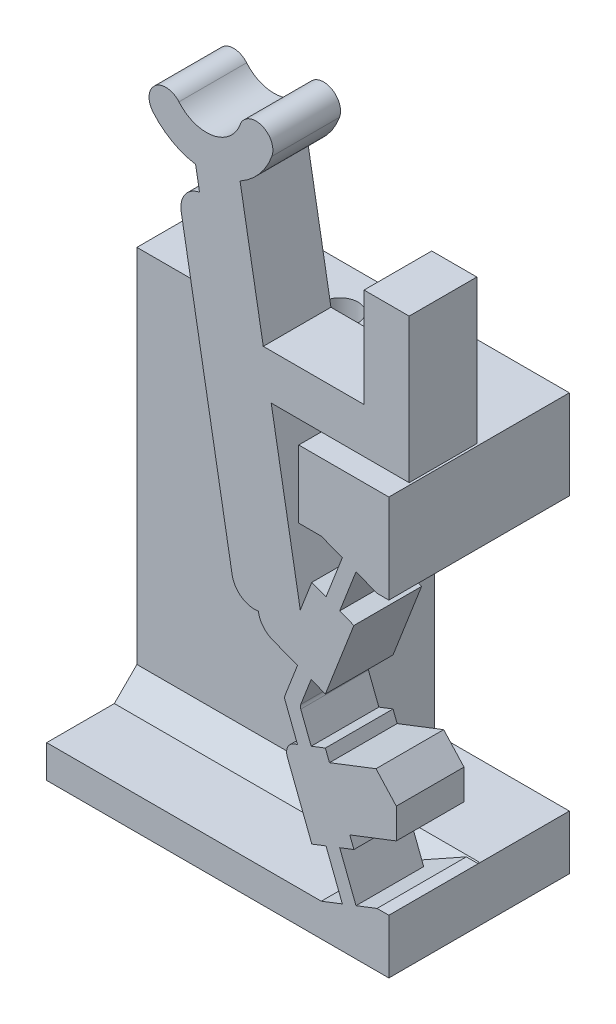
from build123d import *

# Parameters (mm, degrees)
BOSS_SWITCH_BODY_DEPTH            = 3
SKETCH1_W                         = 2.994375291
SKETCH1_H                         = 2.409101515
SKETCH1_W_2                       = 3.994375291
SKETCH1_H_2                       = 3.957767538
BOSS_FLANGE_WIDTH_DEPTH           = 5
BOSS_FLANGE_HEIGHT_REACH          = 36.354
SKETCH2_W                         = 4
SKETCH2_H                         = 3.957767538
SKETCH2_W_2                       = 8
SKETCH2_H_2                       = 1.451333978
SKETCH17_W                        = 15.1675
SKETCH17_H                        = 4
BOSS_FLANGE_SUPPORT_DEPTH         = 13.053634428
CUT_WALL_GAP_DEPTH                = 1
TAP_DRILL_FOR_M2X0_4_TAP1_D       = 1.6
M2_CLEARANCE_HOLE2_D              = 2.4
M2_CLEARANCE_HOLE2_DEPTH          = 13.462735941
CHAMFER_FLANGE_SUPPORT_3_SIZE     = 1
FILLET1_R                         = 1
FILLET2_R                         = 0.5
SKETCH28_W                        = 5.9675
SKETCH28_H                        = 12.095866891
CUT_PRINT_SUPPORT_CLEARANCE_DEPTH = 33.624103931


with BuildPart() as part:
    # Sketch-SwitchBossUp → Boss-Switch Body (new body)
    with BuildSketch(Plane.XY):
        with BuildLine():
            Line((-5.697895702, 26.949658376), (-5.524247524, 25.964850623))
            ThreePointArc((-5.524247524, 25.964850623), (-6.169751391, 25.553619307), (-6.3354071, 24.806394693))
            Line((-6.3354071, 24.806394693), (-4.07798079, 12.003893904))
            ThreePointArc((-4.07798079, 12.003893904), (-3.666749473, 11.358390037), (-2.919524859, 11.192734328))
            Line((-2.919524859, 11.192734328), (-2.816117912, 10.606284387))
            Line((-2.816117912, 10.606284387), (-1.811990528, 10.217060362))
            Line((-1.811990528, 10.217060362), (-1.182618868, 9.973100706))
            Line((-1.182618868, 9.973100706), (-1.735258621, 8.547390389))
            ThreePointArc((-1.735258621, 8.547390389), (-1.752158006, 8.457034961), (-1.735258621, 8.366679532))
            Line((-1.735258621, 8.366679532), (-1.182618868, 6.940969215))
            Line((-1.182618868, 6.940969215), (-1.811990528, 6.697009559))
            Line((-1.811990528, 6.697009559), (-0.547014535, 3.433600952))
            Line((-0.547014535, 3.433600952), (0.082357125, 3.677560608))
            Line((0.082357125, 3.677560608), (0.805200549, 1.81275569))
            Line((0.805200549, 1.81275569), (-0.12720191, 1.451333978))
            Line((-0.12720191, 1.451333978), (-0.12720191, 0))
            Line((-0.12720191, 0), (2.867173381, 0))
            Line((2.867173381, 0), (2.867173381, 2.409101515))
            Line((2.867173381, 2.409101515), (2.343664607, 2.409101515))
            Line((2.343664607, 2.409101515), (1.411262148, 2.047679803))
            Line((1.411262148, 2.047679803), (0.688418723, 3.912484721))
            Line((0.688418723, 3.912484721), (1.317790383, 4.156444377))
            Line((1.317790383, 4.156444377), (1.13533703, 4.627140933))
            Line((1.13533703, 4.627140933), (3.197473995, 5.426475025))
            Line((3.197473995, 5.426475025), (3.197473995, 6.761927069))
            Line((3.197473995, 6.761927069), (2.297289747, 7.748445958))
            Line((2.297289747, 7.748445958), (0.235267743, 6.949156428))
            Line((0.235267743, 6.949156428), (0.05281439, 7.419852984))
            Line((0.05281439, 7.419852984), (-0.57655727, 7.175893328))
            Line((-0.57655727, 7.175893328), (-1.038134762, 8.366679532))
            ThreePointArc((-1.038134762, 8.366679532), (-1.055034148, 8.457034961), (-1.038134762, 8.547390389))
            Line((-1.038134762, 8.547390389), (-0.57655727, 9.738176593))
            Line((-0.57655727, 9.738176593), (0.05281439, 9.494216937))
            Line((0.05281439, 9.494216937), (1.317790383, 12.757625544))
            Line((1.317790383, 12.757625544), (0.688418723, 13.0015852))
            Line((0.688418723, 13.0015852), (1.411262148, 14.866390118))
            Line((1.411262148, 14.866390118), (2.343664607, 14.504968406))
            Line((2.343664607, 14.504968406), (2.867173381, 14.504968406))
            Line((2.867173381, 14.504968406), (2.867173381, 18.462735944))
            Line((2.867173381, 18.462735944), (-0.111637615, 18.462735944))
            Line((-0.111637615, 18.462735944), (-1.12720191, 18.462735944))
            Line((-1.12720191, 18.462735944), (-1.12720191, 15.462735944))
            Line((-1.12720191, 15.462735944), (-0.12720191, 15.462735944))
            Line((-0.12720191, 15.462735944), (0.805200549, 15.101314231))
            Line((0.805200549, 15.101314231), (0.082357125, 13.236509313))
            Line((0.082357125, 13.236509313), (-0.547014535, 13.480468969))
            Line((-0.547014535, 13.480468969), (-1.059112089, 12.159350171))
            Line((-1.059112089, 12.159350171), (-2.346896051, 19.462735944))
            Line((-2.346896051, 19.462735944), (3.767173381, 19.462735944))
            Line((3.767173381, 19.462735944), (3.767173381, 25.857619356))
            Line((3.767173381, 25.857619356), (1.767173381, 25.857619356))
            Line((1.767173381, 25.857619356), (1.767173381, 21.462735944))
            Line((1.767173381, 21.462735944), (-2.699550012, 21.462735944))
            Line((-2.699550012, 21.462735944), (-3.728280196, 27.296954732))
            ThreePointArc((-3.728280196, 27.296954732), (-2.874356585, 27.992742953), (-2.319025652, 28.944012807))
            ThreePointArc((-2.319025652, 28.944012807), (-2.76728001, 29.905297381), (-3.728564583, 29.457043022))
            ThreePointArc((-3.728564583, 29.457043022), (-4.944660137, 28.436617692), (-6.436422172, 28.97957467))
            ThreePointArc((-6.436422172, 28.97957467), (-7.493046212, 29.072017295), (-7.585488837, 28.015393255))
            ThreePointArc((-7.585488837, 28.015393255), (-6.738295005, 27.311426358), (-5.697895702, 26.949658376))
        make_face()
    extrude(amount=BOSS_SWITCH_BODY_DEPTH)

    # Sketch1 → Boss-Flange Width (add)
    with BuildSketch(Plane(origin=(0, 0, 0), x_dir=(-1, 0, 0), z_dir=(0, 0, -1))):
        with Locations((-1.369985736, 1.204550758)):
            Rectangle(SKETCH1_W, SKETCH1_H)
        with Locations((-0.869985736, 16.483852175)):
            Rectangle(SKETCH1_W_2, SKETCH1_H_2)
    extrude(amount=BOSS_FLANGE_WIDTH_DEPTH)

    # Boss-Flange Height: up to this face of the body (flat: up to its plane)
    boss_flange_height_end = Plane(part.part.faces().sort_by_distance((-0.12720191, 1.077409098, -1.438016547))[0])
    # Sketch2 → Boss-Flange Height (add, up to the picked face)
    with BuildSketch(Plane(origin=(-12.300326619, 0, 0), x_dir=(0, 0, -1), z_dir=(1, 0, 0)), mode=Mode.PRIVATE) as boss_flange_height_sk1:
        with Locations((3, 16.483852175)):
            Rectangle(SKETCH2_W, SKETCH2_H)
    boss_flange_height_tool1 = split(extrude(boss_flange_height_sk1.sketch, amount=BOSS_FLANGE_HEIGHT_REACH, mode=Mode.PRIVATE), bisect_by=boss_flange_height_end, keep=Keep.BOTH, mode=Mode.PRIVATE)
    # Sketch2 → Boss-Flange Height (add, up to the picked face)
    with BuildSketch(Plane(origin=(-12.300326619, 0, 0), x_dir=(0, 0, -1), z_dir=(1, 0, 0)), mode=Mode.PRIVATE) as boss_flange_height_sk2:
        with Locations((1, 0.725666989)):
            Rectangle(SKETCH2_W_2, SKETCH2_H_2)
    boss_flange_height_tool2 = split(extrude(boss_flange_height_sk2.sketch, amount=BOSS_FLANGE_HEIGHT_REACH, mode=Mode.PRIVATE), bisect_by=boss_flange_height_end, keep=Keep.BOTH, mode=Mode.PRIVATE)
    add(boss_flange_height_tool1.solids().sort_by(Axis((-12.300327, 16.483852, -3), (1, 0, 0)))[0])
    add(boss_flange_height_tool2.solids().sort_by(Axis((-12.300327, 0.725667, -1), (1, 0, 0)))[0])

    # Sketch17 → Boss-Flange Support (add)
    with BuildSketch(Plane.XZ.offset(-1.451333978)):
        with Locations((-4.716576619, -3)):
            Rectangle(SKETCH17_W, SKETCH17_H)
    extrude(amount=-BOSS_FLANGE_SUPPORT_DEPTH)

    # Sketch27 → Cut-Wall Gap (cut)
    with BuildSketch(Plane.XY):
        Polygon((-0.12720191, 15.462735944), (2.343664607, 14.504968406), (-1.12720191, 14.504968406), (-1.12720191, 15.462735944), align=None)
        Polygon((2.343664607, 2.409101515), (-0.12720191, 2.409101515), (-0.12720191, 1.451333978), align=None)
    extrude(amount=-CUT_WALL_GAP_DEPTH, mode=Mode.SUBTRACT)

    # Tap Drill for M2x0.4 Tap1 (through all)
    with Locations(Plane(origin=(0, 0, 0), x_dir=(-1, 0, 0), z_dir=(0, -1, 0))):
        with Locations((9.300326619, 3), (5.300326619, 3)):
            Hole(TAP_DRILL_FOR_M2X0_4_TAP1_D / 2)

    # M2 Clearance Hole2
    with Locations(Plane.XZ):
        with Locations((-9.300326619, -3), (-5.300326619, -3)):
            Hole(M2_CLEARANCE_HOLE2_D / 2, depth=M2_CLEARANCE_HOLE2_DEPTH)

    # Chamfer-Flange Support 3
    chamfer_flange_support_3_edges = [part.edges().sort_by_distance(p)[0] for p in [
        (-6.213764264, 1.451333978, -1),
    ]]
    chamfer(chamfer_flange_support_3_edges, length=CHAMFER_FLANGE_SUPPORT_3_SIZE)

    # Fillet1
    fillet1_edges = [part.edges().sort_by_distance(p)[0] for p in [
        (-2.816117912, 10.606284387, 1.5),
    ]]
    fillet(fillet1_edges, radius=FILLET1_R)

    # Fillet2
    fillet2_edges = [part.edges().sort_by_distance(p)[0] for p in [
        (-1.811990528, 6.697009559, 1.5),
    ]]
    fillet(fillet2_edges, radius=FILLET2_R)

    # Sketch28 → Cut-Print Support Clearance (cut, through all)
    with BuildSketch(Plane.XY.offset(-1)):
        with Locations((-0.116576619, 8.457034961)):
            Rectangle(SKETCH28_W, SKETCH28_H)
    extrude(amount=-CUT_PRINT_SUPPORT_CLEARANCE_DEPTH, mode=Mode.SUBTRACT)


solid = part.part
